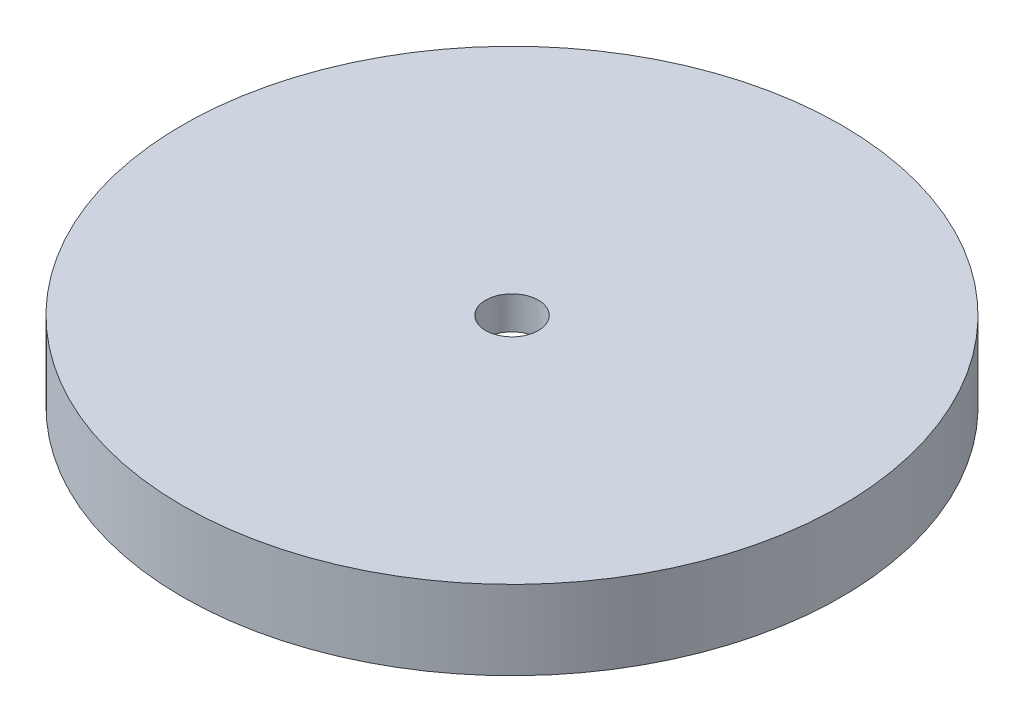
from build123d import *

# Parameters (mm, degrees)
SKETCH1_R           = 50
SKETCH1_R_2         = 40
BOSS_EXTRUDE1_DEPTH = 7
SKETCH2_R           = 50
SKETCH2_R_2         = 4
BOSS_EXTRUDE2_DEPTH = 5


with BuildPart() as part:
    # Sketch1 → Boss-Extrude1 (new body)
    with BuildSketch(Plane(origin=(0, 0, 0), x_dir=(1, 0, 0), z_dir=(0, 1, 0))):
        Circle(SKETCH1_R)
        Circle(SKETCH1_R_2, mode=Mode.SUBTRACT)
    extrude(amount=BOSS_EXTRUDE1_DEPTH)

    # Sketch2 → Boss-Extrude2 (add)
    with BuildSketch(Plane(origin=(0, 7, 0), x_dir=(1, 0, 0), z_dir=(0, 1, 0))):
        Circle(SKETCH2_R)
        Circle(SKETCH2_R_2, mode=Mode.SUBTRACT)
    extrude(amount=BOSS_EXTRUDE2_DEPTH)


solid = part.part
